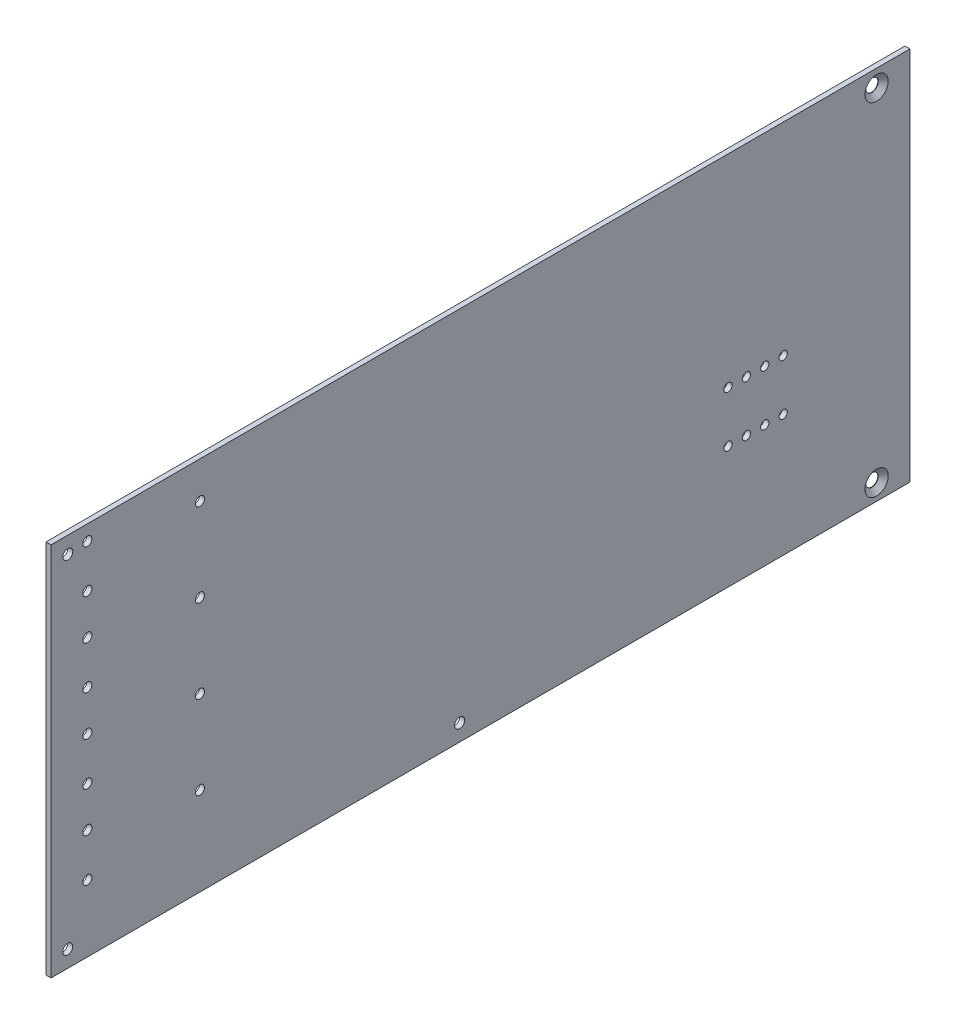
from build123d import *

# Parameters (mm, degrees)
SKETCH1_W                                 = 1.524
SKETCH1_H                                 = 114.3
BOSS_EXTRUDE1_DEPTH                       = 130.81
CSK_FOR_6_FLAT_HEAD_MACHINE_SCREW_2_COUNT = 2
CSK_FOR_6_FLAT_HEAD_MACHINE_SCREW_2_PITCH = 104.14
F_7_64_0_10938_DIAMETER_HOLE1_D           = 2.778252
F_31_0_12_DIAMETER_HOLE1_D                = 3.048
F_39_0_0995_DIAMETER_HOLE1_D              = 2.5273
F_39_0_0995_DIAMETER_HOLE1_DEPTH          = 6.35
F_39_0_0995_DIAMETER_HOLE1_TIP            = 1.26365


with BuildPart() as part:
    # Sketch1 → Boss-Extrude1 (new body, symmetric)
    with BuildSketch(Plane.XY):
        with Locations((-0.762, 0)):
            Rectangle(SKETCH1_W, SKETCH1_H)
    extrude(amount=BOSS_EXTRUDE1_DEPTH, both=True)

    # Sketch3 → CSK for #6 Flat Head Machine Screw (100)1 (revolve, cut)
    with BuildSketch(Plane(origin=(0, 51.943, -120.65), x_dir=(0, 0, -1), z_dir=(0, 1, 0))):
        Polygon((0, 0), (0, 1.524), (1.89865, 1.524), (1.89865, 1.380029791), (3.543305461, 0), align=None)
    csk_for_6_flat_head_machine_screw_100 = revolve(axis=Axis((6.35, 51.943, -120.65), (-1, 0, 0)), mode=Mode.SUBTRACT)

    # CSK for _6 Flat Head Machine Screw _ 2: CSK for #6 Flat Head Machine Screw (100)1 ×2
    with Locations(*[(0, -i * CSK_FOR_6_FLAT_HEAD_MACHINE_SCREW_2_PITCH, 0) for i in range(1, CSK_FOR_6_FLAT_HEAD_MACHINE_SCREW_2_COUNT)]):
        add(csk_for_6_flat_head_machine_screw_100, mode=Mode.SUBTRACT)

    # 7/64 (0.10938) Diameter Hole1 (through all)
    with Locations(Plane.ZY.offset(1.524)):
        with Locations((119.761, 52.5526), (85.471, 45.974), (119.761, 39.4208), (119.761, 27.1526), (85.471, 20.574), (119.761, 14.0208), (119.761, 1.7526), (119.761, -11.3792), (85.471, -4.826), (85.471, -30.226), (119.761, -23.6474), (119.761, -36.7792)):
            Hole(F_7_64_0_10938_DIAMETER_HOLE1_D / 2)

    # #31 (0.12) Diameter Hole1 (through all)
    with Locations(Plane.ZY.offset(1.524)):
        with Locations((125.73, 52.07), (125.73, -52.07), (6.35, -52.07)):
            Hole(F_31_0_12_DIAMETER_HOLE1_D / 2)

    # #39 (0.0995) Diameter Hole1
    with Locations(Plane.ZY.offset(1.524)):
        with Locations((-92.202, -4.445), (-86.5886, -4.445), (-81.0006, -4.445), (-75.3872, -4.445), (-75.3872, -19.939), (-81.0006, -19.939), (-86.5886, -19.939), (-92.202, -19.939)):
            Hole(F_39_0_0995_DIAMETER_HOLE1_D / 2, depth=F_39_0_0995_DIAMETER_HOLE1_DEPTH)
            with Locations((0, 0, -(F_39_0_0995_DIAMETER_HOLE1_DEPTH + F_39_0_0995_DIAMETER_HOLE1_TIP / 2))):  # 90° drill point
                Cone(0, F_39_0_0995_DIAMETER_HOLE1_D / 2, F_39_0_0995_DIAMETER_HOLE1_TIP, mode=Mode.SUBTRACT)


solid = part.part
